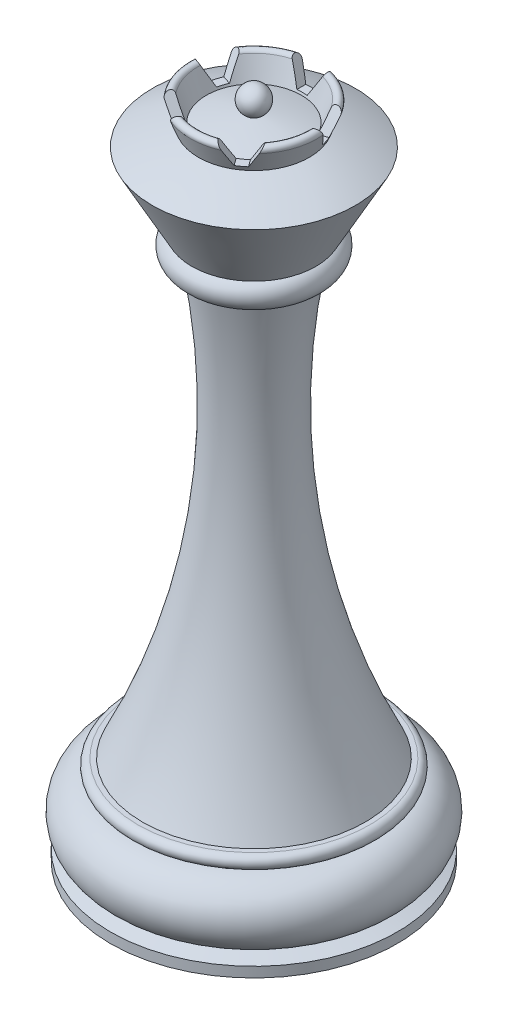
from build123d import *

# Parameters (mm, degrees)
CUT_EXTRUDE2_DEPTH = 66.747958584
CIRPATTERN2_COUNT  = 5


with BuildPart() as part:
    # Sketch1 → Revolve1 (revolve)
    with BuildSketch(Plane.XY):
        with BuildLine():
            Line((0, -9.621899222), (15.450410298, -9.621899222))
            Line((15.450410298, -9.621899222), (15.450410298, -8.530075969))
            Line((15.450410298, -8.530075969), (13.893883706, -8.017710004))
            ThreePointArc((13.893883706, -8.017710004), (15.773602868, -4.193417719), (12.478125528, -1.49186544))
            Line((12.478125528, -1.49186544), (12.478125528, -1.42836544))
            ThreePointArc((12.478125528, -1.42836544), (13.215841354, -0.726095063), (12.5015625, 0))
            Line((12.5015625, 0), (11.997414701, 0))
            ThreePointArc((11.997414701, 0), (5.028058279, 22.703216305), (5.525553365, 46.446856679))
            ThreePointArc((5.525553365, 46.446856679), (7.357777783, 47.302334151), (6.689405525, 49.210780259))
            Line((6.689405525, 49.210780259), (10.941416282, 57.021735688))
            Line((10.941416282, 57.021735688), (0, 57.021735688))
            Line((0, 57.021735688), (0, -9.621899222))
        make_face()
        with BuildLine():
            ThreePointArc((5.121737655, 59.285642311), (5.551352522, 59.164305902), (5.979135599, 59.036661482))
            Line((5.979135599, 59.036661482), (6.828142797, 61.201295923))
            ThreePointArc((6.828142797, 61.201295923), (6.57660569, 61.777479415), (6.000422198, 61.525942308))
            Line((6.000422198, 61.525942308), (5.121737655, 59.285642311))
        make_face()
    revolve(axis=Axis((0, 0, 0), (0, -1, 0)))

    # Sketch8 → Cut-Extrude2 (cut, through all)
    with BuildSketch(Plane.XY):
        Polygon((-0.554871669, 59.518199955), (0.554871669, 59.518199955), (2.014291896, 62.222037417), (-2.014291896, 62.222037417), align=None)
    cut_extrude2 = extrude(amount=-CUT_EXTRUDE2_DEPTH, mode=Mode.SUBTRACT)

    # CirPattern2: Cut-Extrude2 ×5 about axis
    cirpattern2_axis = Axis((0, -9.621899222, 0), (0, 1, 0))
    for i in range(1, CIRPATTERN2_COUNT):
        add(cut_extrude2.rotate(cirpattern2_axis, i * 360 / CIRPATTERN2_COUNT), mode=Mode.SUBTRACT)

    # Sketch1_5 → Revolve3 (revolve)
    with BuildSketch(Plane.XY):
        with BuildLine():
            Line((0, 57.021735688), (10.941416282, 57.021735688))
            ThreePointArc((10.941416282, 57.021735688), (5.911914471, 59.057173953), (0.600293393, 60.164232637))
            ThreePointArc((0.600293393, 60.164232637), (1.400889155, 61.774036009), (0, 62.900947737))
            Line((0, 62.900947737), (0, 57.021735688))
        make_face()
    revolve(axis=Axis((0, 0, 0), (0, -1, 0)))


solid = part.part
